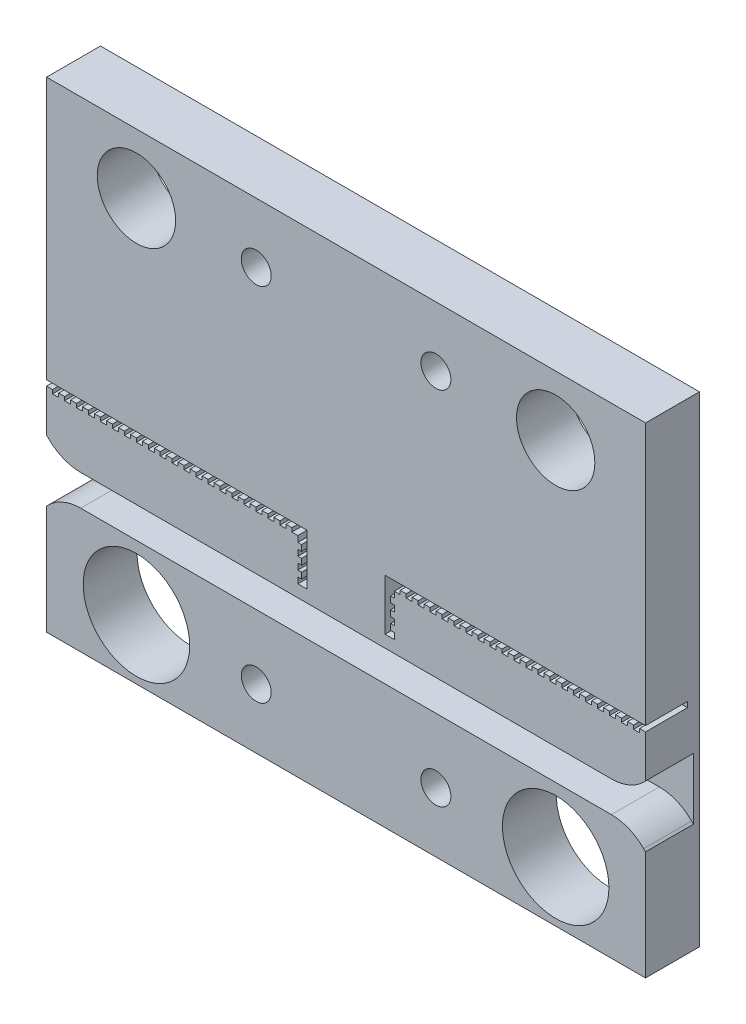
from build123d import *

# Parameters (mm, degrees)
SKETCH1_W           = 100
SKETCH1_H           = 80.26
SKETCH1_R           = 6.5405
SKETCH1_R_2         = 8.89
SKETCH1_R_3         = 2.5
BOSS_EXTRUDE1_DEPTH = 9
CUT_EXTRUDE1_START  = -7
CUT_EXTRUDE1_DEPTH  = 8
SKETCH3_W           = 100
SKETCH3_H           = 5.167106525
CUT_EXTRUDE2_DEPTH  = 8
CHAMFER1_SIZE       = 2.54
FILLET1_R           = 7.62


with BuildPart() as part:
    # Sketch1 → Boss-Extrude1 (new body)
    with BuildSketch(Plane.XY):
        with Locations((52.710746881, 14.822551686)):
            Rectangle(SKETCH1_W, SKETCH1_H)
        with Locations((17.710746881, 44.952551686)):
            Circle(SKETCH1_R, mode=Mode.SUBTRACT)
        with Locations((17.710746881, -15.307448314)):
            Circle(SKETCH1_R_2, mode=Mode.SUBTRACT)
        with Locations((87.710746881, -15.307448314)):
            Circle(SKETCH1_R_2, mode=Mode.SUBTRACT)
        with Locations((87.710746881, 44.952551686)):
            Circle(SKETCH1_R, mode=Mode.SUBTRACT)
        with Locations((37.710746881, 44.952551686)):
            Circle(SKETCH1_R_3, mode=Mode.SUBTRACT)
        with Locations((67.710746881, 44.952551686)):
            Circle(SKETCH1_R_3, mode=Mode.SUBTRACT)
        with Locations((67.710746881, -15.307448314)):
            Circle(SKETCH1_R_3, mode=Mode.SUBTRACT)
        with Locations((37.710746881, -15.307448314)):
            Circle(SKETCH1_R_3, mode=Mode.SUBTRACT)
    extrude(amount=BOSS_EXTRUDE1_DEPTH)

    # Sketch2 → Cut-Extrude1 (cut)
    with BuildSketch(Plane.XY.offset(9).offset(CUT_EXTRUDE1_START)):
        Polygon((46.195950529, 11.184945334), (2.710746881, 11.184945334), (2.710746881, 10.273951686), (3.709601881, 10.273951686), (3.709601881, 9.651651686), (4.708456881, 9.651651686), (4.708456881, 10.273951686), (5.707311881, 10.273951686), (5.707311881, 9.651651686), (6.706166881, 9.651651686), (6.706166881, 10.273951686), (7.705021881, 10.273951686), (7.705021881, 9.651651686), (8.703876881, 9.651651686), (8.703876881, 10.273951686), (9.702731881, 10.273951686), (9.702731881, 9.651651686), (10.701586881, 9.651651686), (10.701586881, 10.273951686), (11.700441881, 10.273951686), (11.700441881, 9.651651686), (12.699296881, 9.651651686), (12.699296881, 10.273951686), (13.698151881, 10.273951686), (13.698151881, 9.651651686), (14.697006881, 9.651651686), (14.697006881, 10.273951686), (15.695861881, 10.273951686), (15.695861881, 9.651651686), (16.694716881, 9.651651686), (16.694716881, 10.273951686), (17.693571881, 10.273951686), (17.693571881, 9.651651686), (18.692426881, 9.651651686), (18.692426881, 10.273951686), (19.691281881, 10.273951686), (19.691281881, 9.651651686), (20.690136881, 9.651651686), (20.690136881, 10.273951686), (21.688991881, 10.273951686), (21.688991881, 9.651651686), (22.687846881, 9.651651686), (22.687846881, 10.273951686), (23.686701881, 10.273951686), (23.686701881, 9.651651686), (24.685556881, 9.651651686), (24.685556881, 10.273951686), (25.684411881, 10.273951686), (25.684411881, 9.651651686), (26.683266881, 9.651651686), (26.683266881, 10.273951686), (27.682121881, 10.273951686), (27.682121881, 9.651651686), (28.680976881, 9.651651686), (28.680976881, 10.273951686), (29.679831881, 10.273951686), (29.679831881, 9.651651686), (30.678686881, 9.651651686), (30.678686881, 10.273951686), (31.677541881, 10.273951686), (31.677541881, 9.651651686), (32.676396881, 9.651651686), (32.676396881, 10.273951686), (33.675251881, 10.273951686), (33.675251881, 9.651651686), (34.674106881, 9.651651686), (34.674106881, 10.273951686), (35.672961881, 10.273951686), (35.672961881, 9.651651686), (36.671816881, 9.651651686), (36.671816881, 10.273951686), (37.670671881, 10.273951686), (37.670671881, 9.651651686), (38.669526881, 9.651651686), (38.669526881, 10.273951686), (39.668381881, 10.273951686), (39.668381881, 9.651651686), (40.667236881, 9.651651686), (40.667236881, 10.273951686), (41.666091881, 10.273951686), (41.666091881, 9.651651686), (42.664946881, 9.651651686), (42.664946881, 10.273951686), (43.663801881, 10.273951686), (43.663801881, 9.651651686), (44.662656881, 9.651651686), (44.662656881, 8.652796686), (45.284956881, 8.652796686), (45.284956881, 7.653941686), (44.662656881, 7.653941686), (44.662656881, 6.655086686), (45.284956881, 6.655086686), (45.284956881, 5.656231686), (44.662656881, 5.656231686), (44.662656881, 4.657376686), (45.284956881, 4.657376686), (45.284956881, 3.658521686), (44.662656881, 3.658521686), (44.662656881, 2.659666686), (46.195950529, 2.659666686), align=None)
    cut_extrude1 = extrude(amount=CUT_EXTRUDE1_DEPTH, mode=Mode.SUBTRACT)

    # Mirror1: Cut-Extrude1 across plane
    add(cut_extrude1.mirror(Plane(origin=(52.710746881, 0, 0), x_dir=(0, 0, 1), z_dir=(1, 0, 0))), mode=Mode.SUBTRACT)

    # Sketch3 → Cut-Extrude2 (cut)
    with BuildSketch(Plane.XY.offset(9)):
        with Locations((52.710746881, -1.946048313)):
            Rectangle(SKETCH3_W, SKETCH3_H)
    extrude(amount=-CUT_EXTRUDE2_DEPTH, mode=Mode.SUBTRACT)

    # Chamfer1
    chamfer1_edges = [part.edges().sort_by_distance(p)[0] for p in [
        (2.710746881, -4.529601576, 5),
        (2.710746881, 0.637504949, 5),
        (102.710746881, 0.637504949, 5),
        (102.710746881, -4.529601576, 5),
    ]]
    chamfer(chamfer1_edges, length=CHAMFER1_SIZE)

    # Fillet1
    fillet1_edges = [part.edges().sort_by_distance(p)[0] for p in [
        (5.250746881, 0.637504949, 5),
        (100.170746881, 0.637504949, 5),
        (5.250746881, -4.529601576, 5),
        (100.170746881, -4.529601576, 5),
    ]]
    fillet(fillet1_edges, radius=FILLET1_R)


solid = part.part
